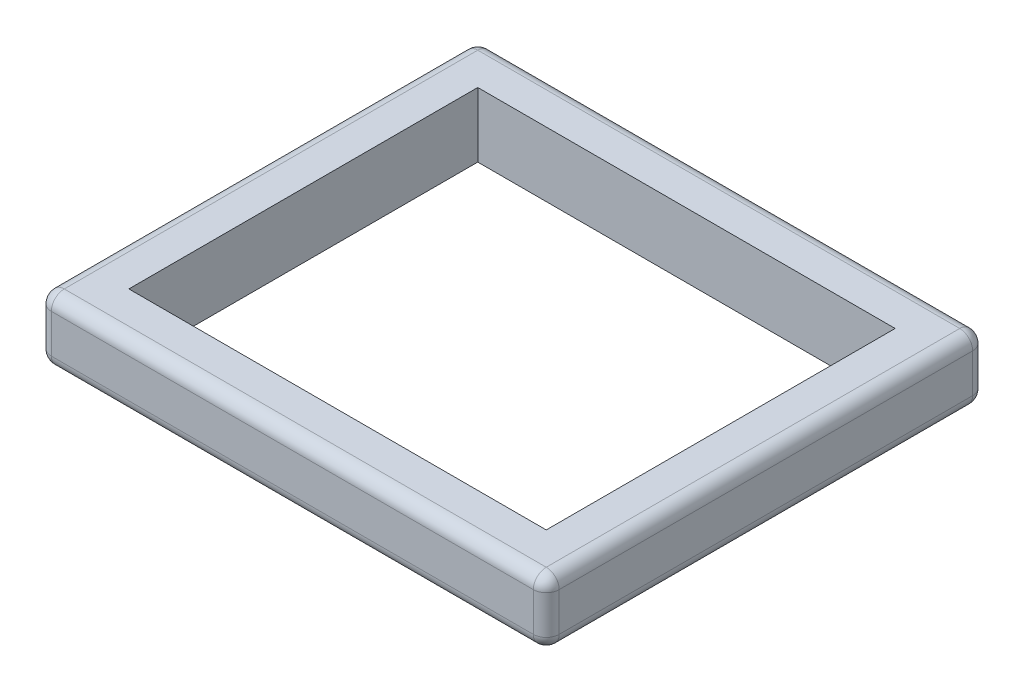
from build123d import *

# Parameters (mm, degrees)
SKETCH1_W           = 998.22
SKETCH1_H           = 863.6
BOSS_EXTRUDE1_DEPTH = 127
SKETCH2_W           = 820.42
SKETCH2_H           = 685.8
CUT_EXTRUDE1_DEPTH  = 127
FILLET1_R           = 25.4


with BuildPart() as part:
    # Sketch1 → Boss-Extrude1 (new body)
    with BuildSketch(Plane(origin=(0, 0, 0), x_dir=(1, 0, 0), z_dir=(0, 1, 0))):
        with Locations((226.123239937, 18.056640537)):
            Rectangle(SKETCH1_W, SKETCH1_H)
    extrude(amount=BOSS_EXTRUDE1_DEPTH)

    # Sketch2 → Cut-Extrude1 (cut)
    with BuildSketch(Plane.XZ):
        with Locations((226.123239937, -18.056640537)):
            Rectangle(SKETCH2_W, SKETCH2_H)
    extrude(amount=-CUT_EXTRUDE1_DEPTH, mode=Mode.SUBTRACT)

    # Fillet1
    fillet1_edges = [part.edges().sort_by_distance(p)[0] for p in [
        (-272.986760063, 63.5, 413.743359463),
        (-272.986760063, 63.5, -449.856640537),
        (-272.986760063, 0, -18.056640537),
        (-272.986760063, 127, -18.056640537),
        (725.233239937, 63.5, 413.743359463),
        (226.123239937, 0, 413.743359463),
        (226.123239937, 127, 413.743359463),
        (725.233239937, 63.5, -449.856640537),
        (226.123239937, 0, -449.856640537),
        (226.123239937, 127, -449.856640537),
        (725.233239937, 0, -18.056640537),
        (725.233239937, 127, -18.056640537),
    ]]
    fillet(fillet1_edges, radius=FILLET1_R)


solid = part.part
